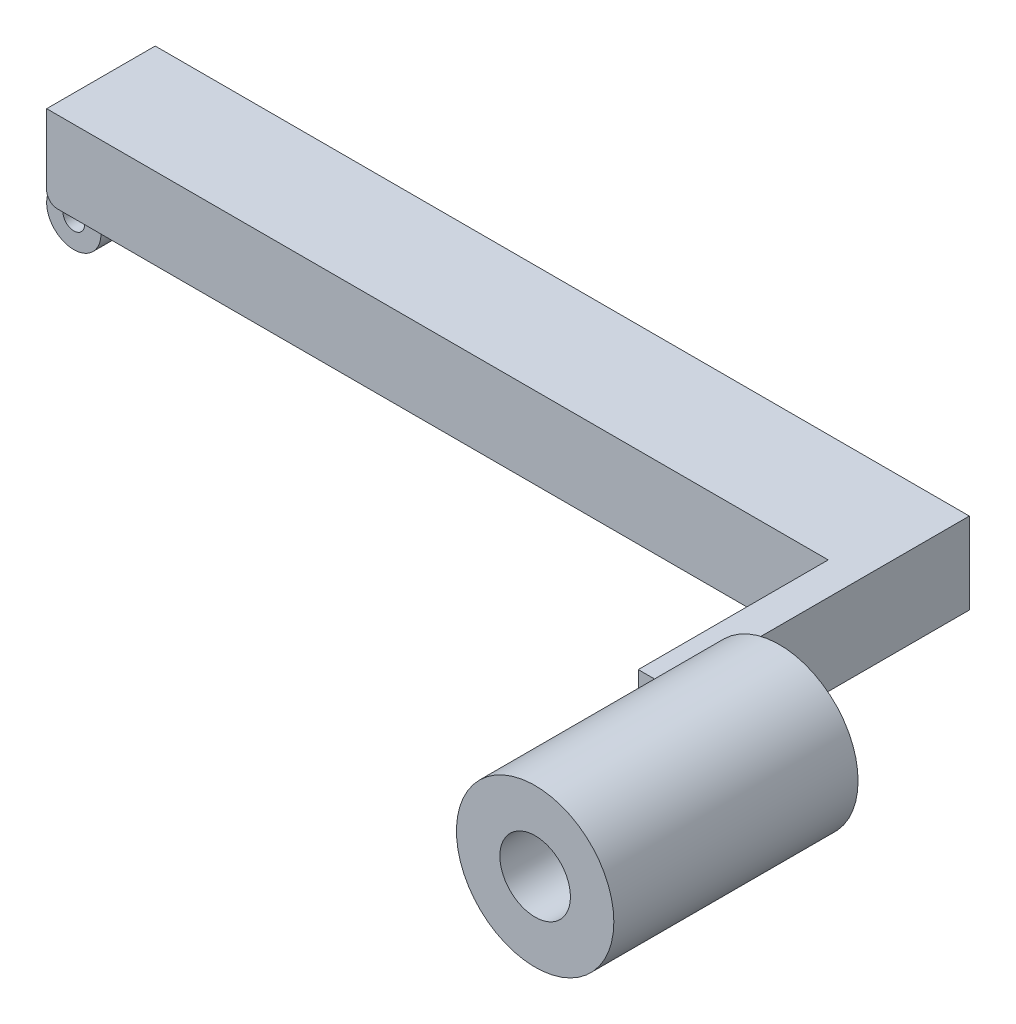
from build123d import *

# Parameters (mm, degrees)
SKETCH4_W                = 20
SKETCH4_H                = 15
BOSS_EXTRUDE1_DEPTH      = 150
SKETCH5_W                = 6
SKETCH5_H                = 15
BOSS_EXTRUDE2_DEPTH      = 35
SKETCH6_R                = 14.5
SKETCH6_R_2              = 6.5
BOSS_EXTRUDE3_DEPTH      = 35
BOSS_EXTRUDE3_DEPTH_BACK = 10
SKETCH7_R                = 2
BOSS_EXTRUDE4_DEPTH      = 5
FILLET1_R                = 2


with BuildPart() as part:
    # Sketch4 → Boss-Extrude1 (new body)
    with BuildSketch(Plane(origin=(0, 0, 0), x_dir=(0, 0, -1), z_dir=(1, 0, 0))):
        Rectangle(SKETCH4_W, SKETCH4_H)
    extrude(amount=BOSS_EXTRUDE1_DEPTH)

    # Sketch5 → Boss-Extrude2 (add)
    with BuildSketch(Plane.XY.offset(10)):
        with Locations((147, 0)):
            Rectangle(SKETCH5_W, SKETCH5_H)
    extrude(amount=BOSS_EXTRUDE2_DEPTH)

    # Sketch6 → Boss-Extrude3 (add, two sides)
    with BuildSketch(Plane.XY.offset(45)) as boss_extrude3_sk:
        with Locations((160, 0)):
            Circle(SKETCH6_R)
        with Locations((160, 0)):
            Circle(SKETCH6_R_2, mode=Mode.SUBTRACT)
    extrude(amount=BOSS_EXTRUDE3_DEPTH)
    extrude(boss_extrude3_sk.sketch, amount=-BOSS_EXTRUDE3_DEPTH_BACK)

    # Sketch7 → Boss-Extrude4 (add, symmetric)
    with BuildSketch(Plane.XY):
        with BuildLine():
            Line((5, -12.5), (5, -7.5))
            Line((5, -7.5), (0, -7.5))
            ThreePointArc((0, -7.5), (-3.535533906, -16.035533906), (5, -12.5))
        make_face()
        with Locations((0, -12.5)):
            Circle(SKETCH7_R, mode=Mode.SUBTRACT)
    extrude(amount=BOSS_EXTRUDE4_DEPTH, both=True)

    # Fillet1
    fillet1_edges = [part.edges().sort_by_distance(p)[0] for p in [
        (0, -7.5, -7.5),
        (0, -7.5, 7.5),
    ]]
    fillet(fillet1_edges, radius=FILLET1_R)


solid = part.part
